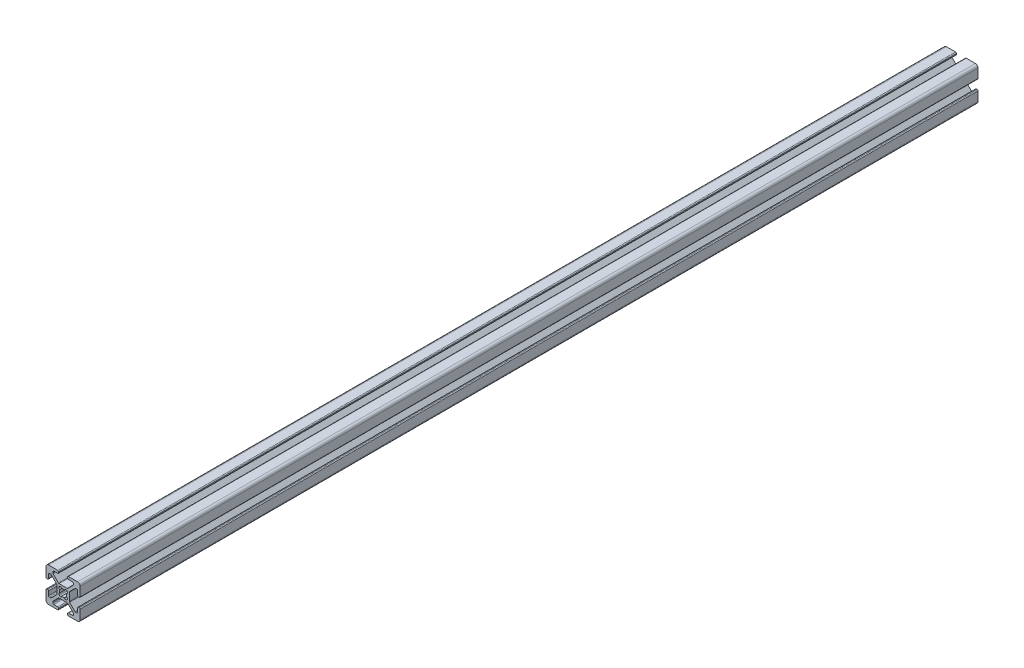
from build123d import *

# Parameters (mm, degrees)
BOSS_EXTRUDE1_DEPTH = 525


with BuildPart() as part:
    # Sketch1 → Boss-Extrude1 (new body)
    with BuildSketch(Plane.XY.offset(4000)):
        with BuildLine():
            Line((10, 3.138), (10, 8.5))
            ThreePointArc((10, 8.5), (9.560660172, 9.560660172), (8.5, 10))
            Line((8.5, 10), (3.138, 10))
            ThreePointArc((3.138, 10), (2.778789755, 9.851210245), (2.63, 9.492))
            Line((2.63, 9.492), (2.63, 9.008))
            ThreePointArc((2.63, 9.008), (2.778789755, 8.648789755), (3.138, 8.5))
            Line((3.138, 8.5), (5.487, 8.5))
            ThreePointArc((5.487, 8.5), (5.846210245, 8.351210245), (5.995, 7.992))
            Line((5.995, 7.992), (5.995, 7.266080661))
            ThreePointArc((5.995, 7.266080661), (5.956330803, 7.071677478), (5.846210245, 6.906870417))
            Line((5.846210245, 6.906870417), (2.743129583, 3.803789755))
            ThreePointArc((2.743129583, 3.803789755), (2.578322522, 3.693669197), (2.383919339, 3.655))
            Line((2.383919339, 3.655), (-2.383919339, 3.655))
            ThreePointArc((-2.383919339, 3.655), (-2.578322522, 3.693669197), (-2.743129583, 3.803789755))
            Line((-2.743129583, 3.803789755), (-5.846210245, 6.906870417))
            ThreePointArc((-5.846210245, 6.906870417), (-5.956330803, 7.071677478), (-5.995, 7.266080661))
            Line((-5.995, 7.266080661), (-5.995, 7.992))
            ThreePointArc((-5.995, 7.992), (-5.846210245, 8.351210245), (-5.487, 8.5))
            Line((-5.487, 8.5), (-3.138, 8.5))
            ThreePointArc((-3.138, 8.5), (-2.778789755, 8.648789755), (-2.63, 9.008))
            Line((-2.63, 9.008), (-2.63, 9.492))
            ThreePointArc((-2.63, 9.492), (-2.778789755, 9.851210245), (-3.138, 10))
            Line((-3.138, 10), (-8.5, 10))
            ThreePointArc((-8.5, 10), (-9.560660172, 9.560660172), (-10, 8.5))
            Line((-10, 8.5), (-10, 3.138))
            ThreePointArc((-10, 3.138), (-9.851210245, 2.778789755), (-9.492, 2.63))
            Line((-9.492, 2.63), (-9.008, 2.63))
            ThreePointArc((-9.008, 2.63), (-8.648789755, 2.778789755), (-8.5, 3.138))
            Line((-8.5, 3.138), (-8.5, 5.487))
            ThreePointArc((-8.5, 5.487), (-8.351210245, 5.846210245), (-7.992, 5.995))
            Line((-7.992, 5.995), (-7.266080661, 5.995))
            ThreePointArc((-7.266080661, 5.995), (-7.071677478, 5.956330803), (-6.906870417, 5.846210245))
            Line((-6.906870417, 5.846210245), (-3.803789755, 2.743129583))
            ThreePointArc((-3.803789755, 2.743129583), (-3.693669197, 2.578322522), (-3.655, 2.383919339))
            Line((-3.655, 2.383919339), (-3.655, -2.383919339))
            ThreePointArc((-3.655, -2.383919339), (-3.693669197, -2.578322522), (-3.803789755, -2.743129583))
            Line((-3.803789755, -2.743129583), (-6.906870417, -5.846210245))
            ThreePointArc((-6.906870417, -5.846210245), (-7.071677478, -5.956330803), (-7.266080661, -5.995))
            Line((-7.266080661, -5.995), (-7.992, -5.995))
            ThreePointArc((-7.992, -5.995), (-8.351210245, -5.846210245), (-8.5, -5.487))
            Line((-8.5, -5.487), (-8.5, -3.138))
            ThreePointArc((-8.5, -3.138), (-8.648789755, -2.778789755), (-9.008, -2.63))
            Line((-9.008, -2.63), (-9.492, -2.63))
            ThreePointArc((-9.492, -2.63), (-9.851210245, -2.778789755), (-10, -3.138))
            Line((-10, -3.138), (-10, -8.5))
            ThreePointArc((-10, -8.5), (-9.560660172, -9.560660172), (-8.5, -10))
            Line((-8.5, -10), (-3.138, -10))
            ThreePointArc((-3.138, -10), (-2.778789755, -9.851210245), (-2.63, -9.492))
            Line((-2.63, -9.492), (-2.63, -9.008))
            ThreePointArc((-2.63, -9.008), (-2.778789755, -8.648789755), (-3.138, -8.5))
            Line((-3.138, -8.5), (-5.487, -8.5))
            ThreePointArc((-5.487, -8.5), (-5.846210245, -8.351210245), (-5.995, -7.992))
            Line((-5.995, -7.992), (-5.995, -7.266080661))
            ThreePointArc((-5.995, -7.266080661), (-5.956330803, -7.071677478), (-5.846210245, -6.906870417))
            Line((-5.846210245, -6.906870417), (-2.743129583, -3.803789755))
            ThreePointArc((-2.743129583, -3.803789755), (-2.578322522, -3.693669197), (-2.383919339, -3.655))
            Line((-2.383919339, -3.655), (2.383919339, -3.655))
            ThreePointArc((2.383919339, -3.655), (2.578322522, -3.693669197), (2.743129583, -3.803789755))
            Line((2.743129583, -3.803789755), (5.846210245, -6.906870417))
            ThreePointArc((5.846210245, -6.906870417), (5.956330803, -7.071677478), (5.995, -7.266080661))
            Line((5.995, -7.266080661), (5.995, -7.992))
            ThreePointArc((5.995, -7.992), (5.846210245, -8.351210245), (5.487, -8.5))
            Line((5.487, -8.5), (3.138, -8.5))
            ThreePointArc((3.138, -8.5), (2.778789755, -8.648789755), (2.63, -9.008))
            Line((2.63, -9.008), (2.63, -9.492))
            ThreePointArc((2.63, -9.492), (2.778789755, -9.851210245), (3.138, -10))
            Line((3.138, -10), (8.5, -10))
            ThreePointArc((8.5, -10), (9.560660172, -9.560660172), (10, -8.5))
            Line((10, -8.5), (10, -3.138))
            ThreePointArc((10, -3.138), (9.851210245, -2.778789755), (9.492, -2.63))
            Line((9.492, -2.63), (9.008, -2.63))
            ThreePointArc((9.008, -2.63), (8.648789755, -2.778789755), (8.5, -3.138))
            Line((8.5, -3.138), (8.5, -5.487))
            ThreePointArc((8.5, -5.487), (8.351210245, -5.846210245), (7.992, -5.995))
            Line((7.992, -5.995), (7.266080661, -5.995))
            ThreePointArc((7.266080661, -5.995), (7.071677478, -5.956330803), (6.906870417, -5.846210245))
            Line((6.906870417, -5.846210245), (3.803789755, -2.743129583))
            ThreePointArc((3.803789755, -2.743129583), (3.693669197, -2.578322522), (3.655, -2.383919339))
            Line((3.655, -2.383919339), (3.655, 2.383919339))
            ThreePointArc((3.655, 2.383919339), (3.693669197, 2.578322522), (3.803789755, 2.743129583))
            Line((3.803789755, 2.743129583), (6.906870417, 5.846210245))
            ThreePointArc((6.906870417, 5.846210245), (7.071677478, 5.956330803), (7.266080661, 5.995))
            Line((7.266080661, 5.995), (7.992, 5.995))
            ThreePointArc((7.992, 5.995), (8.351210245, 5.846210245), (8.5, 5.487))
            Line((8.5, 5.487), (8.5, 3.138))
            ThreePointArc((8.5, 3.138), (8.648789755, 2.778789755), (9.008, 2.63))
            Line((9.008, 2.63), (9.492, 2.63))
            ThreePointArc((9.492, 2.63), (9.851210245, 2.778789755), (10, 3.138))
        make_face()
        with BuildLine():
            Line((-2.124900844, -2.304505966), (-2.304505966, -2.124900844))
            ThreePointArc((-2.304505966, -2.124900844), (-2.505938017, -1.356467811), (-1.935133506, -0.803976718))
            ThreePointArc((-1.935133506, -0.803976718), (-2.0955, 0), (-1.935133506, 0.803976718))
            ThreePointArc((-1.935133506, 0.803976718), (-2.505938017, 1.356467811), (-2.304505966, 2.124900844))
            Line((-2.304505966, 2.124900844), (-2.124900844, 2.304505966))
            ThreePointArc((-2.124900844, 2.304505966), (-1.356467811, 2.505938017), (-0.803976718, 1.935133506))
            ThreePointArc((-0.803976718, 1.935133506), (0, 2.0955), (0.803976718, 1.935133506))
            ThreePointArc((0.803976718, 1.935133506), (1.356467811, 2.505938017), (2.124900844, 2.304505966))
            Line((2.124900844, 2.304505966), (2.304505966, 2.124900844))
            ThreePointArc((2.304505966, 2.124900844), (2.505938017, 1.356467811), (1.935133506, 0.803976718))
            ThreePointArc((1.935133506, 0.803976718), (2.0955, 0), (1.935133506, -0.803976718))
            ThreePointArc((1.935133506, -0.803976718), (2.505938017, -1.356467811), (2.304505966, -2.124900844))
            Line((2.304505966, -2.124900844), (2.124900844, -2.304505966))
            ThreePointArc((2.124900844, -2.304505966), (1.356467811, -2.505938017), (0.803976718, -1.935133506))
            ThreePointArc((0.803976718, -1.935133506), (0, -2.0955), (-0.803976718, -1.935133506))
            ThreePointArc((-0.803976718, -1.935133506), (-1.356467811, -2.505938017), (-2.124900844, -2.304505966))
        make_face(mode=Mode.SUBTRACT)
    extrude(amount=-BOSS_EXTRUDE1_DEPTH)


solid = part.part
